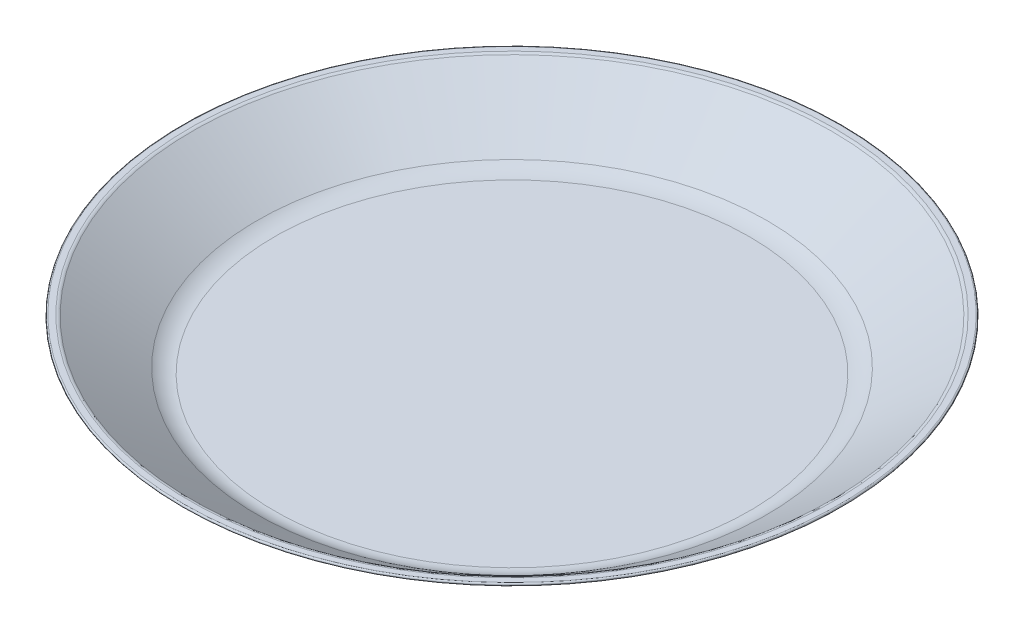
from build123d import *


with BuildPart() as part:
    # ProfileS → Profile (revolve)
    with BuildSketch(Plane.XY):
        with BuildLine():
            Line((0, 0), (90.093578278, 0))
            ThreePointArc((90.093578278, 0), (94.284750443, 0.64207816), (98.091485449, 2.509417731))
            Line((98.091485449, 2.509417731), (124.785639542, 21.089622062))
            ThreePointArc((124.785639542, 21.089622062), (124.977068637, 21.64968472), (124.5, 22))
            Line((124.5, 22), (122.344952056, 22))
            ThreePointArc((122.344952056, 22), (121.746213175, 21.908274549), (121.202393889, 21.641511753))
            Line((121.202393889, 21.641511753), (96.66328774, 4.561307422))
            ThreePointArc((96.66328774, 4.561307422), (93.536326842, 3.027421346), (90.093578278, 2.5))
            Line((90.093578278, 2.5), (0, 2.5))
            Line((0, 2.5), (0, 0))
        make_face()
    revolve(axis=Axis((0, 0, 0), (0, 1, 0)))


solid = part.part
